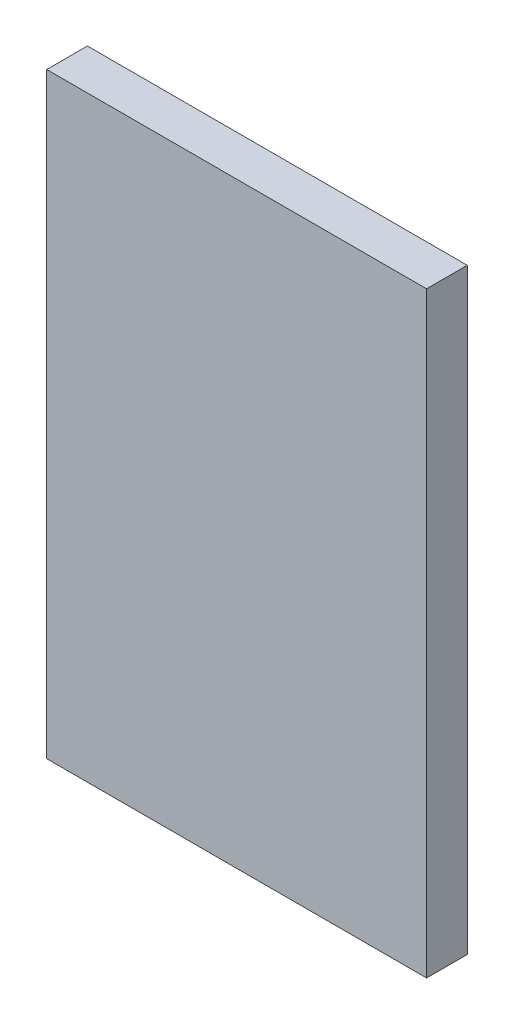
from build123d import *

# Parameters (mm, degrees)
SKETCH1_W           = 177.8
SKETCH1_H           = 279.4
BOSS_EXTRUDE1_DEPTH = 19.05


with BuildPart() as part:
    # Sketch1 → Boss-Extrude1 (new body)
    with BuildSketch(Plane.XY):
        Rectangle(SKETCH1_W, SKETCH1_H)
    extrude(amount=BOSS_EXTRUDE1_DEPTH)


solid = part.part
